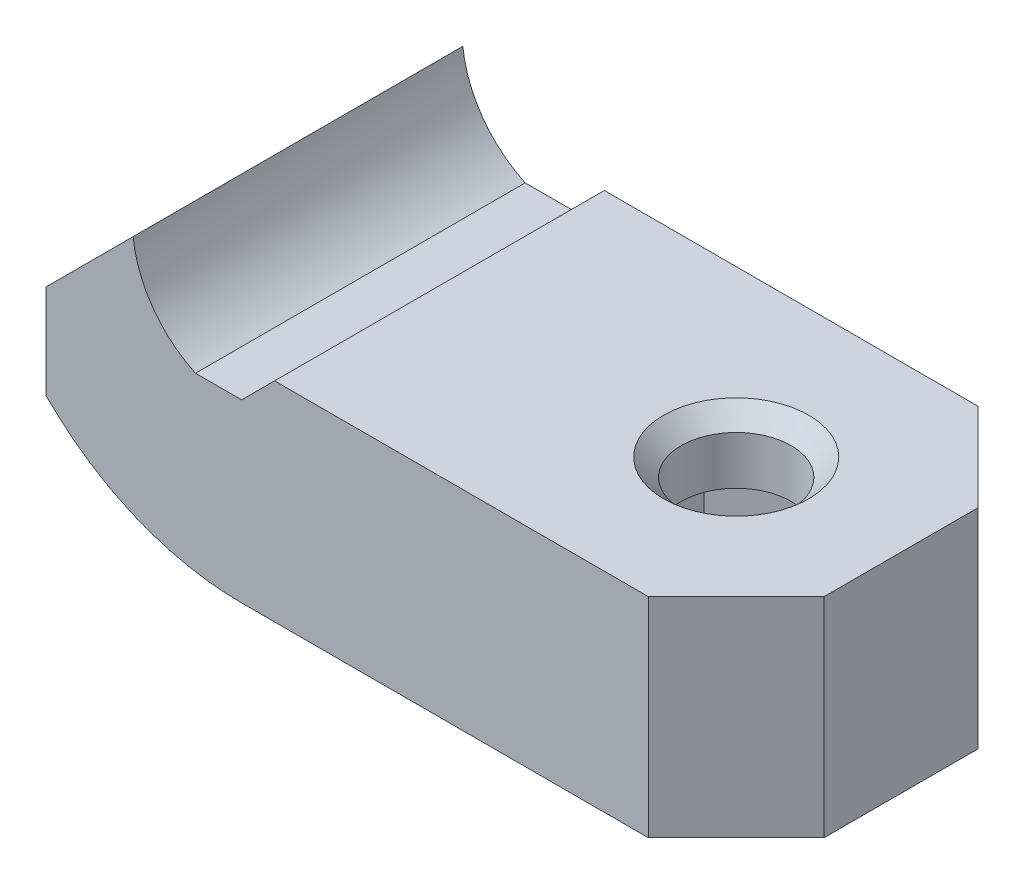
from build123d import *

# Parameters (mm, degrees)
SALIENTE_EXTRUIR1_DEPTH = 7.5
SALIENTE_EXTRUIR2_DEPTH = 15
CROQUIS7_R              = 2.5
CORTAR_EXTRUIR4_DEPTH   = 10.5
CORTAR_EXTRUIR5_START   = -3
CORTAR_EXTRUIR5_DEPTH   = 10
CHAFL_N4_SIZE           = 4
CHAFL_N5_SIZE           = 0.8


with BuildPart() as part:
    # Croquis1 → Saliente-Extruir1 (new body, symmetric)
    with BuildSketch(Plane.XY):
        with BuildLine():
            Line((-8.9, 4), (-4.936786437, 7.963213563))
            ThreePointArc((-4.936786437, 7.963213563), (-4.038051049, 5.609646436), (-2.1, 4))
            Line((-2.1, 4), (0, 4))
            Line((0, 4), (0, -4))
            ThreePointArc((0, -4), (-4.823611651, -3.031815583), (-8.9, -0.277243303))
            Line((-8.9, -0.277243303), (-8.9, 4))
        make_face()
    extrude(amount=SALIENTE_EXTRUIR1_DEPTH, both=True)

    # Croquis6 → Saliente-Extruir2 (add, through all)
    with BuildSketch(Plane(origin=(0, 0, -7.5), x_dir=(-1, 0, 0), z_dir=(0, 0, -1))):
        Polygon((0, 4), (-1.5, 5.5), (-22.5, 5.5), (-22.5, -4), (0, -4), align=None)
    extrude(amount=-SALIENTE_EXTRUIR2_DEPTH)

    # Croquis7 → Cortar-Extruir4 (cut, through all)
    with BuildSketch(Plane(origin=(0, 5.5, 0), x_dir=(1, 0, 0), z_dir=(0, 1, 0))):
        with Locations((15, 0)):
            Circle(CROQUIS7_R)
    extrude(amount=-CORTAR_EXTRUIR4_DEPTH, mode=Mode.SUBTRACT)

    # Croquis8 → Cortar-Extruir5 (cut)
    with BuildSketch(Plane(origin=(0, 5.5, 0), x_dir=(1, 0, 0), z_dir=(0, 1, 0)).offset(CORTAR_EXTRUIR5_START)):
        Polygon((15, 3.983716857), (11.55, 1.991858429), (11.55, -1.991858429), (15, -3.983716857), (18.45, -1.991858429), (18.45, 1.991858429), align=None)
    extrude(amount=-CORTAR_EXTRUIR5_DEPTH, mode=Mode.SUBTRACT)

    # Chaflán4
    chafl_n4_edges = [part.edges().sort_by_distance(p)[0] for p in [
        (22.5, 0.75, 7.5),
        (22.5, 0.75, -7.5),
    ]]
    chamfer(chafl_n4_edges, length=CHAFL_N4_SIZE)

    # Chaflán5
    chafl_n5_edges = [part.edges().sort_by_distance(p)[0] for p in [
        (12.5, 5.5, 0),
        (13.275, -4, -2.987787643),
        (11.55, -4, 0),
        (13.275, -4, 2.987787643),
        (16.725, -4, 2.987787643),
        (18.45, -4, 0),
        (16.725, -4, -2.987787643),
    ]]
    chamfer(chafl_n5_edges, length=CHAFL_N5_SIZE)


solid = part.part
